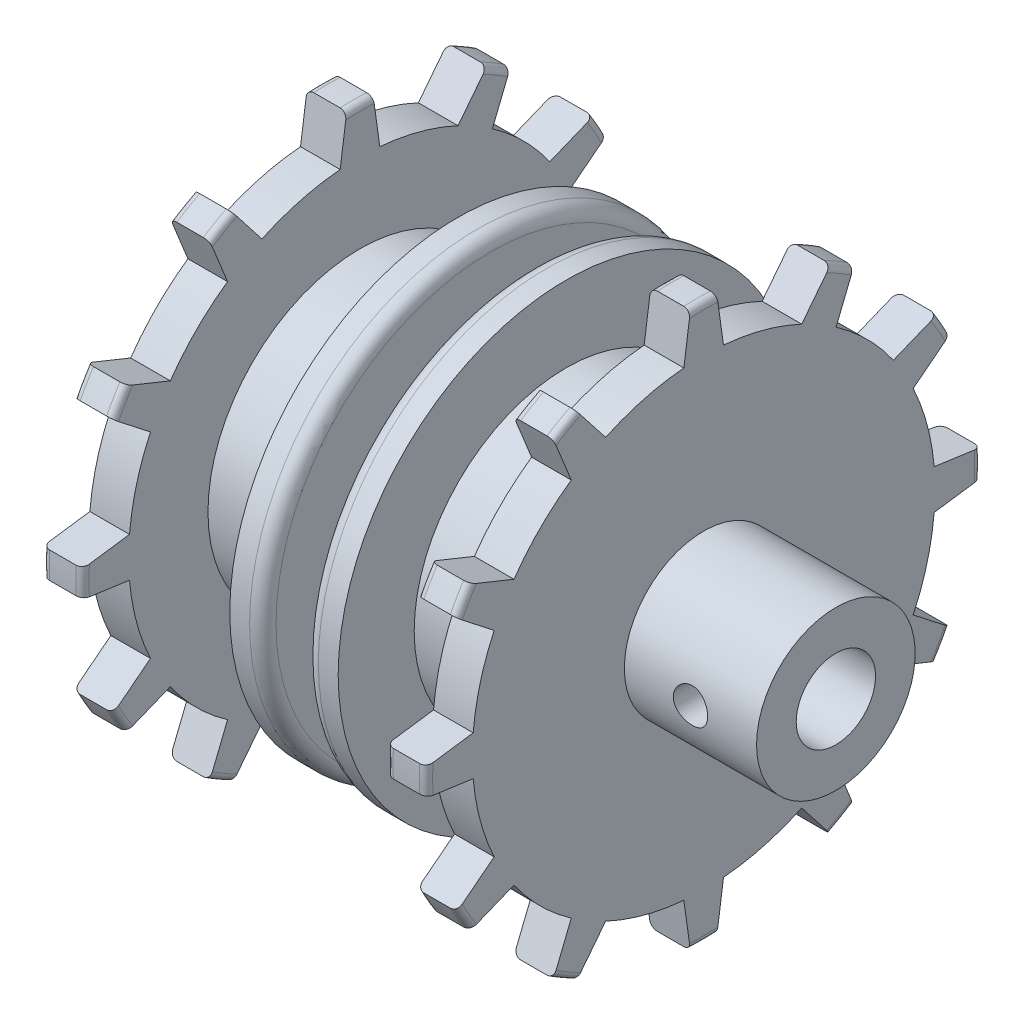
from build123d import *

# Parameters (mm, degrees)
SKETCH_2_R          = 1.3
CUT_EXTRUDE_1_DEPTH = 10
CUT_EXTRUDE_2_DEPTH = 30


with BuildPart() as part:
    # 草图1 → 旋转1 (revolve)
    with BuildSketch(Plane.XY):
        with BuildLine():
            Line((2.6, 17.25), (4.1, 17.25))
            Line((4.1, 17.25), (4.1, 11.5))
            Line((4.1, 11.5), (11.5, 11.5))
            Line((11.5, 11.5), (11.5, 20.5))
            ThreePointArc((11.5, 20.5), (11.646446609, 20.853553391), (12, 21))
            Line((12, 21), (14, 21))
            ThreePointArc((14, 21), (14.353553391, 20.853553391), (14.5, 20.5))
            Line((14.5, 20.5), (14.5, 6))
            Line((14.5, 6), (24.5, 6))
            Line((24.5, 6), (24.5, 3))
            Line((24.5, 3), (10.5, 3))
            Line((10.5, 3), (10.5, 1.5))
            Line((10.5, 1.5), (-2.5, 1.5))
            Line((-2.5, 1.5), (-2.5, 8.4))
            Line((-2.5, 8.4), (-14.5, 8.4))
            Line((-14.5, 8.4), (-14.5, 20.5))
            ThreePointArc((-14.5, 20.5), (-14.353553391, 20.853553391), (-14, 21))
            Line((-14, 21), (-12, 21))
            ThreePointArc((-12, 21), (-11.646446609, 20.853553391), (-11.5, 20.5))
            Line((-11.5, 20.5), (-11.5, 11.5))
            Line((-11.5, 11.5), (-4.1, 11.5))
            Line((-4.1, 11.5), (-4.1, 17.25))
            Line((-4.1, 17.25), (-2.6, 17.25))
            ThreePointArc((-2.6, 17.25), (-1.892893219, 16.957106781), (-1.6, 16.25))
            Line((-1.6, 16.25), (-1.6, 11.5))
            Line((-1.6, 11.5), (1.6, 11.5))
            Line((1.6, 11.5), (1.6, 16.25))
            ThreePointArc((1.6, 16.25), (1.892893219, 16.957106781), (2.6, 17.25))
        make_face()
    revolve(axis=Axis((-17.782832225, 0, 0), (1, 0, 0)))

    # 草图2 → 切除-拉伸1 (cut)
    with BuildSketch(Plane.XY):
        with Locations((19.5, 0)):
            Circle(SKETCH_2_R)
    extrude(amount=CUT_EXTRUDE_1_DEPTH, mode=Mode.SUBTRACT)

    # 草图3 → 切除-拉伸2 (cut)
    with BuildSketch(Plane(origin=(14.5, 0, 0), x_dir=(0, 0, -1), z_dir=(1, 0, 0))):
        with BuildLine():
            Line((14.349668871, 10.016835993), (17.664144554, 11.356972924))
            ThreePointArc((17.664144554, 11.356972924), (14.883266971, 14.888106289), (11.366025404, 17.686533479))
            Line((11.366025404, 17.686533479), (10.016835993, 14.349668871))
            ThreePointArc((10.016835993, 14.349668871), (12.374368671, 12.374368671), (14.349668871, 10.016835993))
        make_face()
        with BuildLine():
            Line((17.435595774, 1.5), (20.976084382, 1.003354785))
            ThreePointArc((20.976084382, 1.003354785), (20.333340433, 5.451844775), (18.686533479, 9.633974596))
            Line((18.686533479, 9.633974596), (15.849668871, 7.418759781))
            ThreePointArc((15.849668871, 7.418759781), (16.90370196, 4.529333289), (17.435595774, 1.5))
        make_face()
        with BuildLine():
            Line((15.849668871, -7.418759781), (18.667499339, -9.619111458))
            ThreePointArc((18.667499339, -9.619111458), (20.335111746, -5.445234143), (21, -1))
            Line((21, -1), (17.435595774, -1.5))
            ThreePointArc((17.435595774, -1.5), (16.90370196, -4.529333289), (15.849668871, -7.418759781))
        make_face()
        with BuildLine():
            Line((10.016835993, -14.349668871), (11.356972924, -17.664144554))
            ThreePointArc((11.356972924, -17.664144554), (14.888106289, -14.883266971), (17.686533479, -11.366025404))
            Line((17.686533479, -11.366025404), (14.349668871, -10.016835993))
            ThreePointArc((14.349668871, -10.016835993), (12.374368671, -12.374368671), (10.016835993, -14.349668871))
        make_face()
        with BuildLine():
            Line((1.5, -17.435595774), (1.003354785, -20.976084382))
            ThreePointArc((1.003354785, -20.976084382), (5.451844775, -20.333340433), (9.633974596, -18.686533479))
            Line((9.633974596, -18.686533479), (7.418759781, -15.849668871))
            ThreePointArc((7.418759781, -15.849668871), (4.529333289, -16.90370196), (1.5, -17.435595774))
        make_face()
        with BuildLine():
            Line((-7.418759781, -15.849668871), (-9.619111458, -18.667499339))
            ThreePointArc((-9.619111458, -18.667499339), (-5.445234143, -20.335111746), (-1, -21))
            Line((-1, -21), (-1.5, -17.435595774))
            ThreePointArc((-1.5, -17.435595774), (-4.529333289, -16.90370196), (-7.418759781, -15.849668871))
        make_face()
        with BuildLine():
            Line((-14.349668871, -10.016835993), (-17.664144554, -11.356972924))
            ThreePointArc((-17.664144554, -11.356972924), (-14.883266971, -14.888106289), (-11.366025404, -17.686533479))
            Line((-11.366025404, -17.686533479), (-10.016835993, -14.349668871))
            ThreePointArc((-10.016835993, -14.349668871), (-12.374368671, -12.374368671), (-14.349668871, -10.016835993))
        make_face()
        with BuildLine():
            Line((-17.435595774, -1.5), (-20.976084382, -1.003354785))
            ThreePointArc((-20.976084382, -1.003354785), (-20.333340433, -5.451844775), (-18.686533479, -9.633974596))
            Line((-18.686533479, -9.633974596), (-15.849668871, -7.418759781))
            ThreePointArc((-15.849668871, -7.418759781), (-16.90370196, -4.529333289), (-17.435595774, -1.5))
        make_face()
        with BuildLine():
            Line((-15.849668871, 7.418759781), (-18.667499339, 9.619111458))
            ThreePointArc((-18.667499339, 9.619111458), (-20.335111746, 5.445234143), (-21, 1))
            Line((-21, 1), (-17.435595774, 1.5))
            ThreePointArc((-17.435595774, 1.5), (-16.90370196, 4.529333289), (-15.849668871, 7.418759781))
        make_face()
        with BuildLine():
            Line((-10.016835993, 14.349668871), (-11.356972924, 17.664144554))
            ThreePointArc((-11.356972924, 17.664144554), (-14.888106289, 14.883266971), (-17.686533479, 11.366025404))
            Line((-17.686533479, 11.366025404), (-14.349668871, 10.016835993))
            ThreePointArc((-14.349668871, 10.016835993), (-12.374368671, 12.374368671), (-10.016835993, 14.349668871))
        make_face()
        with BuildLine():
            Line((7.418759781, 15.849668871), (9.619111458, 18.667499339))
            ThreePointArc((9.619111458, 18.667499339), (5.445234143, 20.335111746), (1, 21))
            Line((1, 21), (1.5, 17.435595774))
            ThreePointArc((1.5, 17.435595774), (4.529333289, 16.90370196), (7.418759781, 15.849668871))
        make_face()
        with BuildLine():
            Line((-1.5, 17.435595774), (-1.003354785, 20.976084382))
            ThreePointArc((-1.003354785, 20.976084382), (-5.451844775, 20.333340433), (-9.633974596, 18.686533479))
            Line((-9.633974596, 18.686533479), (-7.418759781, 15.849668871))
            ThreePointArc((-7.418759781, 15.849668871), (-4.529333289, 16.90370196), (-1.5, 17.435595774))
        make_face()
    extrude(amount=-CUT_EXTRUDE_2_DEPTH, mode=Mode.SUBTRACT)


solid = part.part
